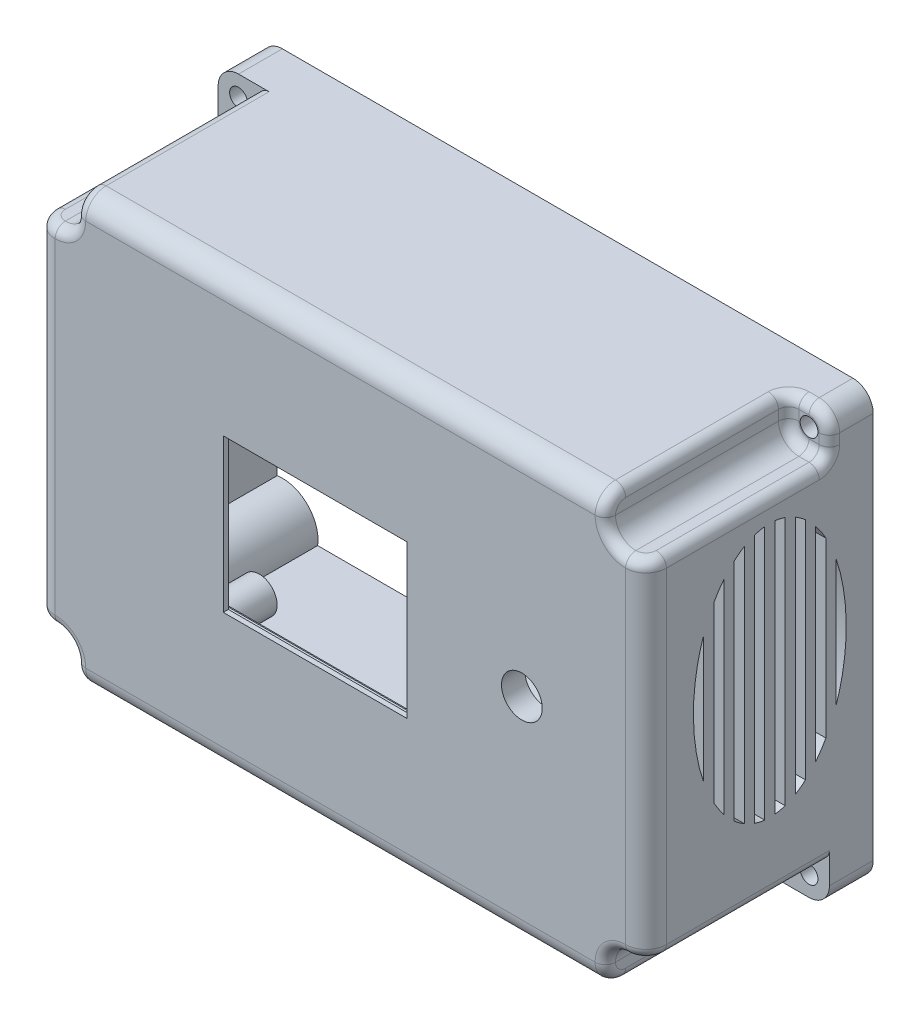
from build123d import *

# Parameters (mm, degrees)
SKETCH1_W               = 120
SKETCH1_H               = 84
SKETCH1_R               = 4
SKETCH1_W_2             = 45.62
SKETCH1_H_2             = 34.02
BOSS_EXTRUDE1_DEPTH     = 2.4
SKETCH2_W               = 120
SKETCH2_H               = 84
SKETCH2_R               = 4
SKETCH2_W_2             = 36.12
SKETCH2_H_2             = 30.02
BOSS_EXTRUDE2_DEPTH     = 1
SKETCH3_W               = 120
SKETCH3_H               = 84
SKETCH3_R               = 4
SKETCH3_W_2             = 55.62
SKETCH3_H_2             = 36.02
BOSS_EXTRUDE3_DEPTH     = 1.2
SKETCH4_W               = 3
SKETCH4_H               = 24.02
CUT_EXTRUDE1_DEPTH      = 2.5
SKETCH5_R               = 1.2
CUT_EXTRUDE2_DEPTH      = 2
SKETCH6_W               = 7
SKETCH6_H               = 20
SKETCH6_R               = 1.75
BOSS_EXTRUDE4_DEPTH     = 4.5
SKETCH8_R               = 3.5
SKETCH8_R_2             = 1.75
BOSS_EXTRUDE6_DEPTH     = 14
SKETCH9_W               = 120
SKETCH9_H               = 84
SKETCH9_W_2             = 114
SKETCH9_H_2             = 78
BOSS_EXTRUDE7_DEPTH     = 40
FILLET1_R               = 4
SKETCH10_R              = 4
BOSS_EXTRUDE8_DEPTH     = 40
SKETCH11_R              = 1.75
CUT_EXTRUDE3_DEPTH      = 45.6
BOSS_EXTRUDE9_DEPTH     = 40
CUT_EXTRUDE4_DEPTH      = 36
FILLET3_R               = 2
SKETCH14_W              = 15.5
SKETCH14_H              = 8
CUT_EXTRUDE5_DEPTH      = 4.0000001
BOSS_EXTRUDE10_DEPTH    = 3
CUT_EXTRUDE6_DEPTH      = 1.0000001
CUT_EXTRUDE6_DEPTH_BACK = 121
SKETCH17_R              = 3.5
SKETCH17_R_2            = 1.75
BOSS_EXTRUDE11_DEPTH    = 14


with BuildPart() as part:
    # Sketch1 → Boss-Extrude1 (new body)
    with BuildSketch(Plane.XY):
        with Locations((7.19, 0.01)):
            Rectangle(SKETCH1_W, SKETCH1_H)
        with Locations((42.81, 0)):
            Circle(SKETCH1_R, mode=Mode.SUBTRACT)
        Rectangle(SKETCH1_W_2, SKETCH1_H_2, mode=Mode.SUBTRACT)
    extrude(amount=BOSS_EXTRUDE1_DEPTH)

    # Sketch2 → Boss-Extrude2 (add)
    with BuildSketch(Plane.XY.offset(2.4)):
        with Locations((7.19, 0.01)):
            Rectangle(SKETCH2_W, SKETCH2_H)
        with Locations((42.81, 0)):
            Circle(SKETCH2_R, mode=Mode.SUBTRACT)
        with Locations((2.25, 0)):
            Rectangle(SKETCH2_W_2, SKETCH2_H_2, mode=Mode.SUBTRACT)
    extrude(amount=BOSS_EXTRUDE2_DEPTH)

    # Sketch3 → Boss-Extrude3 (add)
    with BuildSketch(Plane(origin=(0, 0, 0), x_dir=(-1, 0, 0), z_dir=(0, 0, -1))):
        with Locations((-7.19, 0.01)):
            Rectangle(SKETCH3_W, SKETCH3_H)
        with Locations((-42.81, 0)):
            Circle(SKETCH3_R, mode=Mode.SUBTRACT)
        Rectangle(SKETCH3_W_2, SKETCH3_H_2, mode=Mode.SUBTRACT)
    extrude(amount=BOSS_EXTRUDE3_DEPTH)

    # Sketch4 → Cut-Extrude1 (cut)
    with BuildSketch(Plane(origin=(0, 0, 0), x_dir=(-1, 0, 0), z_dir=(0, 0, -1))):
        with Locations((-26.31, 0)):
            Rectangle(SKETCH4_W, SKETCH4_H)
    extrude(amount=-CUT_EXTRUDE1_DEPTH, mode=Mode.SUBTRACT)

    # Sketch5 → Cut-Extrude2 (cut)
    with BuildSketch(Plane(origin=(0, 0, 0), x_dir=(-1, 0, 0), z_dir=(0, 0, -1))):
        with Locations((-25.81, 16.01)):
            Circle(SKETCH5_R)
        with Locations((25.575055949, 16.01)):
            Circle(SKETCH5_R)
        with Locations((25.575055949, -16.379754449)):
            Circle(SKETCH5_R)
        with Locations((-25.81, -16.379754449)):
            Circle(SKETCH5_R)
    extrude(amount=-CUT_EXTRUDE2_DEPTH, mode=Mode.SUBTRACT)

    # Sketch6 → Boss-Extrude4 (add)
    with BuildSketch(Plane(origin=(0, 0, -1.2), x_dir=(-1, 0, 0), z_dir=(0, 0, -1))):
        with Locations((-52.91, 2)):
            Rectangle(SKETCH6_W, SKETCH6_H)
        with Locations((-51.41, -5)):
            Circle(SKETCH6_R, mode=Mode.SUBTRACT)
        with Locations((-51.41, 9)):
            Circle(SKETCH6_R, mode=Mode.SUBTRACT)
    extrude(amount=BOSS_EXTRUDE4_DEPTH)

    # Sketch8 → Boss-Extrude6 (add)
    with BuildSketch(Plane(origin=(0, 0, -1.2), x_dir=(-1, 0, 0), z_dir=(0, 0, -1))):
        with Locations((27.336063182, 25.01)):
            Circle(SKETCH8_R)
        with Locations((27.336063182, 25.01)):
            Circle(SKETCH8_R_2, mode=Mode.SUBTRACT)
        with Locations((-36.163936818, 25.01)):
            Circle(SKETCH8_R)
        with Locations((-36.163936818, 25.01)):
            Circle(SKETCH8_R_2, mode=Mode.SUBTRACT)
        with Locations((-36.163936818, -27.06)):
            Circle(SKETCH8_R)
        with Locations((-36.163936818, -27.06)):
            Circle(SKETCH8_R_2, mode=Mode.SUBTRACT)
        with Locations((27.336063182, -27.06)):
            Circle(SKETCH8_R)
        with Locations((27.336063182, -27.06)):
            Circle(SKETCH8_R_2, mode=Mode.SUBTRACT)
    extrude(amount=BOSS_EXTRUDE6_DEPTH)

    # Sketch9 → Boss-Extrude7 (add)
    with BuildSketch(Plane(origin=(0, 0, -1.2), x_dir=(-1, 0, 0), z_dir=(0, 0, -1))):
        with Locations((-7.19, 0.01)):
            Rectangle(SKETCH9_W, SKETCH9_H)
        with Locations((-7.19, 0.01)):
            Rectangle(SKETCH9_W_2, SKETCH9_H_2, mode=Mode.SUBTRACT)
    extrude(amount=BOSS_EXTRUDE7_DEPTH)

    # Fillet1
    fillet1_edges = [part.edges().sort_by_distance(p)[0] for p in [
        (-52.81, 0.01, 3.4),
        (7.19, -41.99, 3.4),
        (67.19, 0.01, 3.4),
        (7.19, 42.01, 3.4),
        (-52.81, 42.01, -18.9),
        (67.19, 42.01, -18.9),
        (67.19, -41.99, -18.9),
        (-52.81, -41.99, -18.9),
    ]]
    fillet(fillet1_edges, radius=FILLET1_R)

    # Sketch10 → Boss-Extrude8 (add)
    with BuildSketch(Plane(origin=(0, 0, -41.2), x_dir=(-1, 0, 0), z_dir=(0, 0, -1))):
        with Locations((-63.19, 38.01)):
            Circle(SKETCH10_R)
        with Locations((48.81, -37.99)):
            Circle(SKETCH10_R)
        with Locations((48.81, 38.01)):
            Circle(SKETCH10_R)
        with Locations((-63.19, -37.99)):
            Circle(SKETCH10_R)
    extrude(amount=-BOSS_EXTRUDE8_DEPTH)

    # Sketch11 → Cut-Extrude3 (cut, through all)
    with BuildSketch(Plane(origin=(0, 0, -41.2), x_dir=(-1, 0, 0), z_dir=(0, 0, -1))):
        with Locations((-63.19, 38.01)):
            Circle(SKETCH11_R)
        with Locations((48.81, 38.01)):
            Circle(SKETCH11_R)
        with Locations((48.81, -37.99)):
            Circle(SKETCH11_R)
        with Locations((-63.19, -37.99)):
            Circle(SKETCH11_R)
    extrude(amount=-CUT_EXTRUDE3_DEPTH, mode=Mode.SUBTRACT)

    # Sketch12 → Boss-Extrude9 (add)
    with BuildSketch(Plane(origin=(0, 0, -41.2), x_dir=(-1, 0, 0), z_dir=(0, 0, -1))):
        with BuildLine():
            Line((41.88179677, 39.01), (44.937016654, 39.01))
            ThreePointArc((44.937016654, 39.01), (45.981572875, 35.181572875), (49.81, 34.137016654))
            Line((49.81, 34.137016654), (49.81, 31.08179677))
            ThreePointArc((49.81, 31.08179677), (43.860252532, 33.060252532), (41.88179677, 39.01))
        make_face()
        with BuildLine():
            Line((-59.317016654, 39.01), (-56.26179677, 39.01))
            ThreePointArc((-56.26179677, 39.01), (-58.240252532, 33.060252532), (-64.19, 31.08179677))
            Line((-64.19, 31.08179677), (-64.19, 34.137016654))
            ThreePointArc((-64.19, 34.137016654), (-60.361572875, 35.181572875), (-59.317016654, 39.01))
        make_face()
        with BuildLine():
            Line((-59.317016654, -38.99), (-56.26179677, -38.99))
            ThreePointArc((-56.26179677, -38.99), (-58.240252532, -33.040252532), (-64.19, -31.06179677))
            Line((-64.19, -31.06179677), (-64.19, -34.117016654))
            ThreePointArc((-64.19, -34.117016654), (-60.361572875, -35.161572875), (-59.317016654, -38.99))
        make_face()
        with BuildLine():
            Line((41.88179677, -38.99), (44.937016654, -38.99))
            ThreePointArc((44.937016654, -38.99), (45.981572875, -35.161572875), (49.81, -34.117016654))
            Line((49.81, -34.117016654), (49.81, -31.06179677))
            ThreePointArc((49.81, -31.06179677), (43.860252532, -33.040252532), (41.88179677, -38.99))
        make_face()
    extrude(amount=-BOSS_EXTRUDE9_DEPTH)

    # Sketch13 → Cut-Extrude4 (cut)
    with BuildSketch(Plane.XY.offset(3.4)):
        with BuildLine():
            Line((-48.81, -33.99), (-52.81, -33.99))
            Line((-52.81, -33.99), (-52.81, -37.99))
            ThreePointArc((-52.81, -37.99), (-51.638427125, -40.818427125), (-48.81, -41.99))
            Line((-48.81, -41.99), (-44.81, -41.99))
            Line((-44.81, -41.99), (-44.81, -37.99))
            ThreePointArc((-44.81, -37.99), (-45.981572875, -35.161572875), (-48.81, -33.99))
        make_face()
        with BuildLine():
            Line((63.19, -33.99), (67.19, -33.99))
            Line((67.19, -33.99), (67.19, -37.99))
            ThreePointArc((67.19, -37.99), (66.018427125, -40.818427125), (63.19, -41.99))
            Line((63.19, -41.99), (59.19, -41.99))
            Line((59.19, -41.99), (59.19, -37.99))
            ThreePointArc((59.19, -37.99), (60.361572875, -35.161572875), (63.19, -33.99))
        make_face()
        with BuildLine():
            Line((59.19, 38.01), (59.19, 42.01))
            Line((59.19, 42.01), (63.19, 42.01))
            ThreePointArc((63.19, 42.01), (66.018427125, 40.838427125), (67.19, 38.01))
            Line((67.19, 38.01), (67.19, 34.01))
            Line((67.19, 34.01), (63.19, 34.01))
            ThreePointArc((63.19, 34.01), (60.361572875, 35.181572875), (59.19, 38.01))
        make_face()
        with BuildLine():
            Line((-48.81, 34.01), (-52.81, 34.01))
            Line((-52.81, 34.01), (-52.81, 38.01))
            ThreePointArc((-52.81, 38.01), (-51.638427125, 40.838427125), (-48.81, 42.01))
            Line((-48.81, 42.01), (-44.81, 42.01))
            Line((-44.81, 42.01), (-44.81, 38.01))
            ThreePointArc((-44.81, 38.01), (-45.981572875, 35.181572875), (-48.81, 34.01))
        make_face()
    extrude(amount=-CUT_EXTRUDE4_DEPTH, mode=Mode.SUBTRACT)

    # Fillet3
    fillet3_edges = [part.edges().sort_by_distance(p)[0] for p in [
        (66.018427125, 40.838427125, -32.6),
        (67.19, 36.01, -32.6),
        (61.19, 42.01, -32.6),
        (65.19, 34.01, -32.6),
        (60.361572875, 35.181572875, -32.6),
        (67.19, 34.01, -16.6),
        (66.018427125, 34.01, 2.228427125),
        (60.361572875, 35.181572875, 3.4),
        (67.19, -33.99, -16.6),
        (66.018427125, -33.99, 2.228427125),
        (60.361572875, -35.161572875, 3.4),
        (59.19, -40.818427125, 2.228427125),
        (-44.81, -41.99, -16.6),
        (-44.81, -40.818427125, 2.228427125),
        (-45.981572875, -35.161572875, 3.4),
        (-51.638427125, -33.99, 2.228427125),
        (-44.81, 42.01, -16.6),
        (-44.81, 40.838427125, 2.228427125),
        (-45.981572875, 35.181572875, 3.4),
        (-51.638427125, 34.01, 2.228427125),
        (59.19, 42.01, -16.6),
        (59.19, 40.01, -32.6),
        (59.19, 40.838427125, 2.228427125),
        (59.19, -41.99, -16.6),
        (-52.81, -33.99, -16.6),
        (-52.81, 34.01, -16.6),
    ]]
    fillet(fillet3_edges, radius=FILLET3_R)

    # Sketch14 → Cut-Extrude5 (cut, through all)
    with BuildSketch(Plane(origin=(-49.81, 0, 0), x_dir=(0, 0, -1), z_dir=(1, 0, 0))):
        with Locations((21.794310202, -27.06179677)):
            Rectangle(SKETCH14_W, SKETCH14_H)
    extrude(amount=-CUT_EXTRUDE5_DEPTH, mode=Mode.SUBTRACT)

    # Sketch15 → Boss-Extrude10 (add)
    with BuildSketch(Plane.ZY.offset(52.81)):
        Polygon((-16.744310202, -31.06179677), (-14.044310202, -31.06179677), (-14.044310202, -28.26179677), align=None)
        Polygon((-16.744310202, -23.06179677), (-14.044310202, -23.06179677), (-14.044310202, -25.86179677), align=None)
    extrude(amount=-BOSS_EXTRUDE10_DEPTH)

    # Sketch16 → Cut-Extrude6 (cut, two sides)
    with BuildSketch(Plane.ZY.offset(52.81)) as cut_extrude6_sk:
        with BuildLine():
            Line((-33.9, 16.94539452), (-33.9, -7.998988059))
            add(Edge.make_bspline(
                [(-33.9, 16.94539452), (-38.207692308, 4.47320323), (-33.9, -7.998988059)],
                knots=[4.190074159, 4.190074159, 4.190074159, 5.234703802, 5.234703802, 5.234703802], degree=2, weights=[1, 0.866666667, 1]))
        make_face()
        with BuildLine():
            Line((-31.9, 21.469934942), (-31.9, -12.523528482))
            add(Edge.make_bspline(
                [(-31.9, -12.523528482), (-30.981176584, -14.17532604), (-29.9, -15.52679677)],
                knots=[5.45997333, 5.45997333, 5.45997333, 5.639684198, 5.639684198, 5.639684198], degree=2, weights=[1, 0.995965716, 1]))
            Line((-29.9, -15.52679677), (-29.9, 24.47320323))
            add(Edge.make_bspline(
                [(-29.9, 24.47320323), (-30.981176584, 23.121732501), (-31.9, 21.469934942)],
                knots=[3.785093762, 3.785093762, 3.785093762, 3.964804631, 3.964804631, 3.964804631], degree=2, weights=[1, 0.995965716, 1]))
        make_face()
        with BuildLine():
            Line((-27.9, 26.584035166), (-27.9, -17.637628705))
            add(Edge.make_bspline(
                [(-27.9, -17.637628705), (-26.931947467, -18.488941933), (-25.9, -19.097022809)],
                knots=[5.797667185, 5.797667185, 5.797667185, 5.943348398, 5.943348398, 5.943348398], degree=2, weights=[1, 0.997348296, 1]))
            Line((-25.9, -19.097022809), (-25.9, 28.04342927))
            add(Edge.make_bspline(
                [(-25.9, 28.04342927), (-26.931947467, 27.435348393), (-27.9, 26.584035166)],
                knots=[3.481429563, 3.481429563, 3.481429563, 3.627110776, 3.627110776, 3.627110776], degree=2, weights=[1, 0.997348296, 1]))
        make_face()
        with BuildLine():
            Line((-23.9, 28.968100658), (-23.9, -20.021694198))
            add(Edge.make_bspline(
                [(-23.9, -20.021694198), (-22.909091661, -20.358808061), (-21.9, -20.471179348)],
                knots=[6.081827386, 6.081827386, 6.081827386, 6.216469159, 6.216469159, 6.216469159], degree=2, weights=[1, 0.997734805, 1]))
            Line((-21.9, -20.471179348), (-21.9, 29.417585809))
            add(Edge.make_bspline(
                [(-21.9, 29.417585809), (-22.909091661, 29.305214521), (-23.9, 28.968100658)],
                knots=[3.208308802, 3.208308802, 3.208308802, 3.342950574, 3.342950574, 3.342950574], degree=2, weights=[1, 0.997734805, 1]))
        make_face()
        with BuildLine():
            Line((-19.9, 29.417585809), (-19.9, -20.471179348))
            add(Edge.make_bspline(
                [(-19.9, -20.471179348), (-18.890908339, -20.358808061), (-17.9, -20.021694198)],
                knots=[0.066716148, 0.066716148, 0.066716148, 0.201357921, 0.201357921, 0.201357921], degree=2, weights=[1, 0.997734805, 1]))
            Line((-17.9, -20.021694198), (-17.9, 28.968100658))
            add(Edge.make_bspline(
                [(-17.9, 28.968100658), (-18.890908339, 29.305214521), (-19.9, 29.417585809)],
                knots=[2.940234733, 2.940234733, 2.940234733, 3.074876505, 3.074876505, 3.074876505], degree=2, weights=[1, 0.997734805, 1]))
        make_face()
        with BuildLine():
            Line((-15.9, 28.04342927), (-15.9, -19.097022809))
            add(Edge.make_bspline(
                [(-15.9, -19.097022809), (-14.868052533, -18.488941933), (-13.9, -17.637628705)],
                knots=[0.339836909, 0.339836909, 0.339836909, 0.485518122, 0.485518122, 0.485518122], degree=2, weights=[1, 0.997348296, 1]))
            Line((-13.9, -17.637628705), (-13.9, 26.584035166))
            add(Edge.make_bspline(
                [(-13.9, 26.584035166), (-14.868052533, 27.435348393), (-15.9, 28.04342927)],
                knots=[2.656074531, 2.656074531, 2.656074531, 2.801755744, 2.801755744, 2.801755744], degree=2, weights=[1, 0.997348296, 1]))
        make_face()
        with BuildLine():
            Line((-11.9, 24.47320323), (-11.9, -15.52679677))
            add(Edge.make_bspline(
                [(-11.9, -15.52679677), (-10.818823416, -14.17532604), (-9.9, -12.523528482)],
                knots=[0.643501109, 0.643501109, 0.643501109, 0.823211977, 0.823211977, 0.823211977], degree=2, weights=[1, 0.995965716, 1]))
            Line((-9.9, -12.523528482), (-9.9, 21.469934942))
            add(Edge.make_bspline(
                [(-9.9, 21.469934942), (-10.818823416, 23.121732501), (-11.9, 24.47320323)],
                knots=[2.318380676, 2.318380676, 2.318380676, 2.498091545, 2.498091545, 2.498091545], degree=2, weights=[1, 0.995965716, 1]))
        make_face()
        with BuildLine():
            Line((-7.9, 16.94539452), (-7.9, -7.998988059))
            add(Edge.make_bspline(
                [(-7.9, -7.998988059), (-3.592307692, 4.47320323), (-7.9, 16.94539452)],
                knots=[1.048481505, 1.048481505, 1.048481505, 2.093111149, 2.093111149, 2.093111149], degree=2, weights=[1, 0.866666667, 1]))
        make_face()
    extrude(amount=CUT_EXTRUDE6_DEPTH, mode=Mode.SUBTRACT)
    extrude(cut_extrude6_sk.sketch, amount=-CUT_EXTRUDE6_DEPTH_BACK, mode=Mode.SUBTRACT)

    # Sketch17 → Boss-Extrude11 (add)
    with BuildSketch(Plane(origin=(0, 0, -15.2), x_dir=(-1, 0, 0), z_dir=(0, 0, -1))):
        with Locations((-36.163936818, 25.01)):
            Circle(SKETCH17_R)
        with Locations((-36.163936818, 25.01)):
            Circle(SKETCH17_R_2, mode=Mode.SUBTRACT)
        with Locations((27.336063182, 25.01)):
            Circle(SKETCH17_R)
        with Locations((27.336063182, 25.01)):
            Circle(SKETCH17_R_2, mode=Mode.SUBTRACT)
    extrude(amount=-BOSS_EXTRUDE11_DEPTH)


solid = part.part
